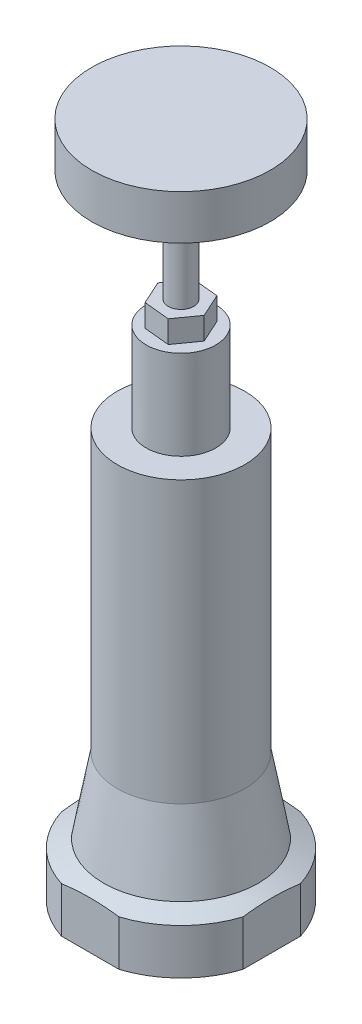
from build123d import *

# Parameters (mm, degrees)
SKETCH2_OUTSIDE_W   = 84.116
SKETCH2_OUTSIDE_H   = 84.116
SKETCH2_OUTSIDE_W_2 = 51.689
SKETCH2_OUTSIDE_H_2 = 51.689
EXTRUDE1_DEPTH      = 17.78
SKETCH3_R           = 9.906
EXTRUDE2_DEPTH      = 25.4
EXTRUDE3_DEPTH      = 6.35
SKETCH5_R           = 3.6195
EXTRUDE4_DEPTH      = 12.7
SKETCH6_R           = 3.6195
EXTRUDE5_DEPTH      = 31.75
SKETCH7_R           = 25.4
EXTRUDE6_DEPTH      = 12.7


with BuildPart() as part:
    # Sketch1 → Revolve1 (revolve)
    with BuildSketch(Plane.XY):
        Polygon((0, 0), (-18.1356, 0), (-18.1356, -79.883), (-22.0345, -101.219), (-27.1145, -103.505), (-27.1145, -116.459), (0, -116.459), align=None)
    revolve(axis=Axis((0, -116.459, 0), (0, 1, 0)))

    # Sketch2 outside → Extrude1 (cut)
    with BuildSketch(Plane.XZ.offset(116.459)):
        Rectangle(SKETCH2_OUTSIDE_W, SKETCH2_OUTSIDE_H)
        Rectangle(SKETCH2_OUTSIDE_W_2, SKETCH2_OUTSIDE_H_2, mode=Mode.SUBTRACT)
    extrude(amount=-EXTRUDE1_DEPTH, mode=Mode.SUBTRACT)

    # Sketch3 → Extrude2 (add)
    with BuildSketch(Plane(origin=(0, 0, 0), x_dir=(1, 0, 0), z_dir=(0, 1, 0))):
        Circle(SKETCH3_R)
    extrude(amount=EXTRUDE2_DEPTH)

    # Sketch4 → Extrude3 (add)
    with BuildSketch(Plane(origin=(0, 25.4, 0), x_dir=(1, 0, 0), z_dir=(0, 1, 0))):
        Polygon((-4.265485733, -5.963972233), (3.032208595, -6.676005121), (7.297694328, -0.712032888), (4.265485733, 5.963972233), (-3.032208595, 6.676005121), (-7.297694328, 0.712032888), align=None)
    extrude(amount=EXTRUDE3_DEPTH)

    # Sketch5 → Extrude4 (cut)
    with BuildSketch(Plane(origin=(0, 31.75, 0), x_dir=(1, 0, 0), z_dir=(0, 1, 0))):
        Circle(SKETCH5_R)
    extrude(amount=-EXTRUDE4_DEPTH, mode=Mode.SUBTRACT)


with BuildPart() as body_2:
    # Sketch6 → Extrude5 (new body)
    with BuildSketch(Plane(origin=(0, 31.75, 0), x_dir=(1, 0, 0), z_dir=(0, 1, 0))):
        Circle(SKETCH6_R)
    extrude(amount=EXTRUDE5_DEPTH)

    # Sketch7 → Extrude6 (add)
    with BuildSketch(Plane(origin=(0, 63.5, 0), x_dir=(1, 0, 0), z_dir=(0, 1, 0))):
        Circle(SKETCH7_R)
    extrude(amount=EXTRUDE6_DEPTH)


solid = Compound([part.part, body_2.part])
